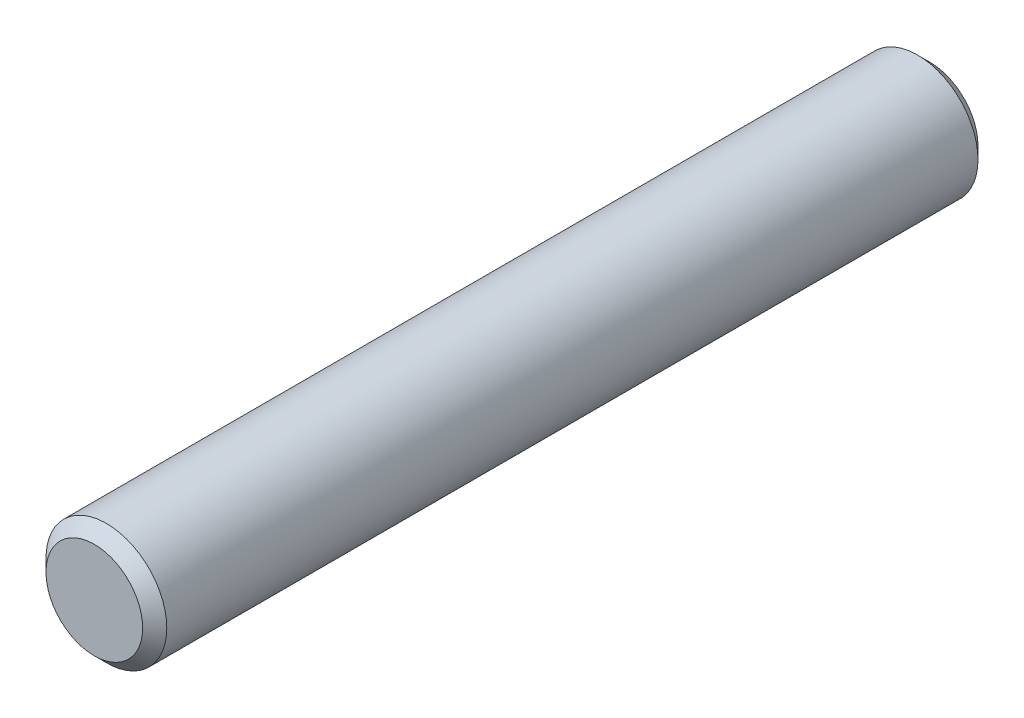
from build123d import *

# Parameters (mm, degrees)
SKETCH1_R      = 3
EXTRUDE1_DEPTH = 20.75
CHAMFER1_SIZE  = 0.6


with BuildPart() as part:
    # Sketch1 → Extrude1 (new body, symmetric)
    with BuildSketch(Plane.XY):
        Circle(SKETCH1_R)
    extrude(amount=EXTRUDE1_DEPTH, both=True)

    # Chamfer1
    chamfer1_edges = [part.edges().sort_by_distance(p)[0] for p in [
        (-3, 0, -20.75),
        (-3, 0, 20.75),
    ]]
    chamfer(chamfer1_edges, length=CHAMFER1_SIZE)


solid = part.part
